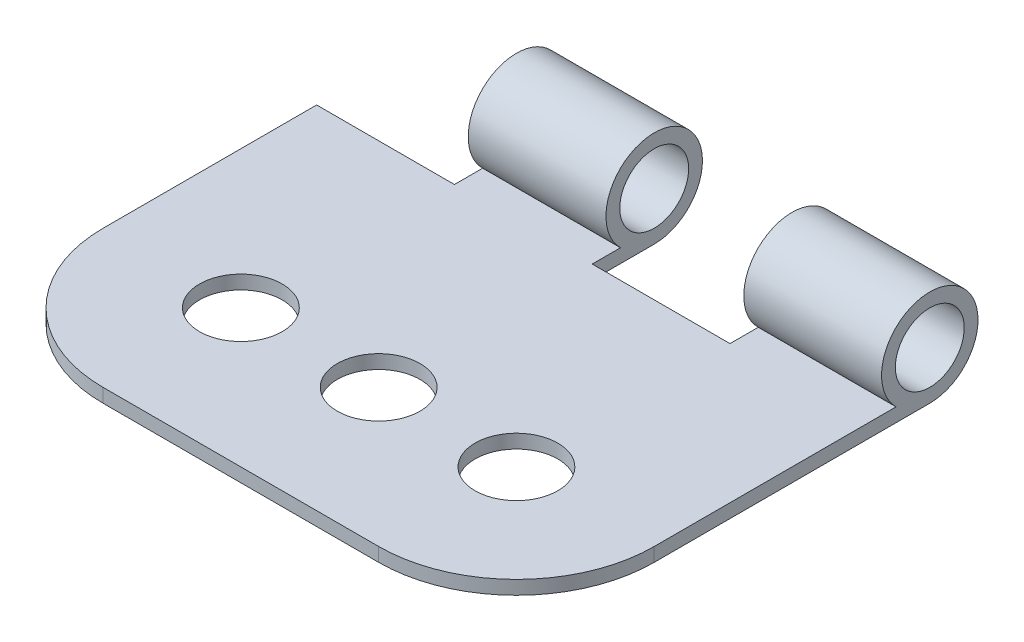
from build123d import *

# Parameters (mm, degrees)
ESQUISSE1_R             = 2.5
BOSS_EXTRU_1_DEPTH      = 40
ESQUISSE2_W             = 10
ESQUISSE2_H             = 7
ENL_V_MAT_EXTRU_1_DEPTH = 44.5
ESQUISSE3_W             = 10
ESQUISSE3_H             = 8
ENL_V_MAT_EXTRU_2_DEPTH = 40
ESQUISSE4_R             = 3
ENL_V_MAT_EXTRU_3_DEPTH = 2


with BuildPart() as part:
    # Esquisse1 → Boss.-Extru.1 (new body)
    with BuildSketch(Plane(origin=(0, 0, 0), x_dir=(0, 0, -1), z_dir=(1, 0, 0))):
        with BuildLine():
            Line((-57.619622055, -2.842276543), (-20.069111797, -2.842276543))
            ThreePointArc((-20.069111797, -2.842276543), (-16.296746399, 2.898093806), (-17.619622055, -3.842276543))
            Line((-17.619622055, -3.842276543), (-57.619622055, -3.842276543))
            Line((-57.619622055, -3.842276543), (-57.619622055, -2.842276543))
        make_face()
        with Locations((-17.619622055, -0.342276543)):
            Circle(ESQUISSE1_R, mode=Mode.SUBTRACT)
    extrude(amount=BOSS_EXTRU_1_DEPTH)

    # Esquisse2 → Enlèv. mat.-Extru.1 (cut, through all)
    with BuildSketch(Plane.XY.offset(57.619622055)):
        with Locations((25, 0.657723457)):
            Rectangle(ESQUISSE2_W, ESQUISSE2_H)
        with Locations((5, 0.657723457)):
            Rectangle(ESQUISSE2_W, ESQUISSE2_H)
    extrude(amount=-ENL_V_MAT_EXTRU_1_DEPTH, mode=Mode.SUBTRACT)

    # Esquisse3 → Enlèv. mat.-Extru.2 (cut)
    with BuildSketch(Plane(origin=(0, -2.842276543, 0), x_dir=(1, 0, 0), z_dir=(0, 1, 0))):
        with Locations((5, -18.119622055)):
            Rectangle(ESQUISSE3_W, ESQUISSE3_H)
        with Locations((25, -18.119622055)):
            Rectangle(ESQUISSE3_W, ESQUISSE3_H)
    extrude(amount=-ENL_V_MAT_EXTRU_2_DEPTH, mode=Mode.SUBTRACT)

    # Esquisse4 → Enlèv. mat.-Extru.3 (cut, through all)
    with BuildSketch(Plane(origin=(0, -2.842276543, 0), x_dir=(1, 0, 0), z_dir=(0, 1, 0))):
        with Locations(Location((10, -37.619622055, 0), (0, 0, 270))):  # turned: the seam where the file's is
            Circle(ESQUISSE4_R)
        with Locations(Location((20, -37.619622055, 0), (0, 0, 270))):  # turned: the seam where the file's is
            Circle(ESQUISSE4_R)
        with Locations(Location((30, -37.619622055, 0), (0, 0, 270))):  # turned: the seam where the file's is
            Circle(ESQUISSE4_R)
        with BuildLine():
            Line((10, -47.619622055), (30, -47.619622055))
            ThreePointArc((30, -47.619622055), (37.071067812, -44.690689866), (40, -37.619622055))
            Line((40, -37.619622055), (40, -57.619622055))
            Line((40, -57.619622055), (0, -57.619622055))
            Line((0, -57.619622055), (0, -37.619622055))
            ThreePointArc((0, -37.619622055), (2.928932188, -44.690689866), (10, -47.619622055))
        make_face()
    extrude(amount=-ENL_V_MAT_EXTRU_3_DEPTH, mode=Mode.SUBTRACT)


solid = part.part
